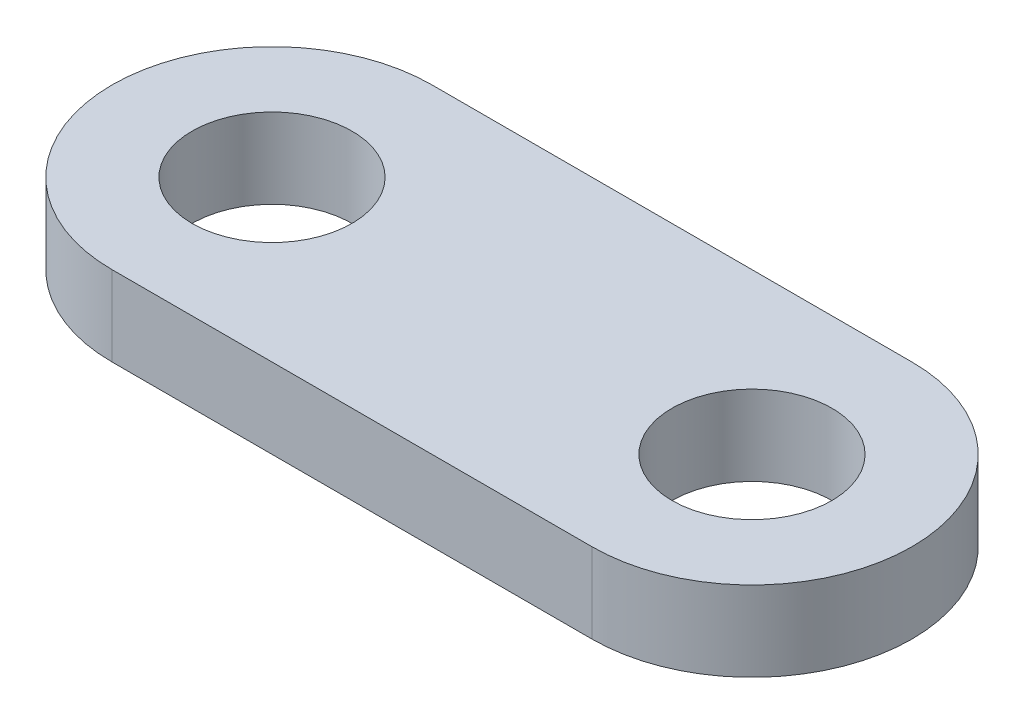
from build123d import *

# Parameters (mm, degrees)
SKETCH1_R           = 5
BOSS_EXTRUDE1_DEPTH = 5


with BuildPart() as part:
    # Sketch1 → Boss-Extrude1 (new body)
    with BuildSketch(Plane(origin=(0, 0, 0), x_dir=(1, 0, 0), z_dir=(0, 1, 0))):
        with BuildLine():
            Line((0, 10), (30, 10))
            ThreePointArc((30, 10), (40, 0), (30, -10))
            Line((30, -10), (0, -10))
            ThreePointArc((0, -10), (-10, 0), (0, 10))
        make_face()
        Circle(SKETCH1_R, mode=Mode.SUBTRACT)
        with Locations((30, 0)):
            Circle(SKETCH1_R, mode=Mode.SUBTRACT)
    extrude(amount=BOSS_EXTRUDE1_DEPTH)


solid = part.part
